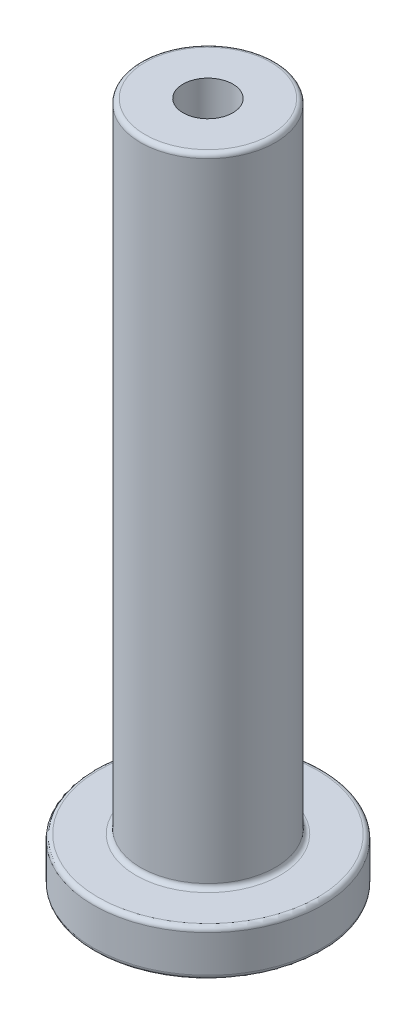
from build123d import *

# Parameters (mm, degrees)
SKETCH1_R           = 12.4
BOSS_EXTRUDE1_DEPTH = 5
SKETCH2_R           = 7.3
BOSS_EXTRUDE2_DEPTH = 69
SKETCH3_R           = 2.7
CUT_EXTRUDE1_DEPTH  = 75
CUT_EXTRUDE2_DEPTH  = 3
FILLET1_R           = 0.5


with BuildPart() as part:
    # Sketch1 → Boss-Extrude1 (new body)
    with BuildSketch(Plane(origin=(0, 0, 0), x_dir=(1, 0, 0), z_dir=(0, 1, 0))):
        Circle(SKETCH1_R)
    extrude(amount=BOSS_EXTRUDE1_DEPTH)

    # Sketch2 → Boss-Extrude2 (add)
    with BuildSketch(Plane(origin=(0, 5, 0), x_dir=(1, 0, 0), z_dir=(0, 1, 0))):
        Circle(SKETCH2_R)
    extrude(amount=BOSS_EXTRUDE2_DEPTH)

    # Sketch3 → Cut-Extrude1 (cut, through all)
    with BuildSketch(Plane(origin=(0, 74, 0), x_dir=(1, 0, 0), z_dir=(0, 1, 0))):
        Circle(SKETCH3_R)
    extrude(amount=-CUT_EXTRUDE1_DEPTH, mode=Mode.SUBTRACT)

    # Sketch4 → Cut-Extrude2 (cut)
    with BuildSketch(Plane.XZ):
        Polygon((-4.38019792, 2.081793981), (-3.992985433, -2.752465682), (0.387212487, -4.834259663), (4.38019792, -2.081793981), (3.992985433, 2.752465682), (-0.387212487, 4.834259663), align=None)
    extrude(amount=-CUT_EXTRUDE2_DEPTH, mode=Mode.SUBTRACT)

    # Fillet1
    fillet1_edges = [part.edges().sort_by_distance(p)[0] for p in [
        (-12.4, 0, 0),
        (-12.4, 5, 0),
        (-7.3, 5, 0),
        (-7.3, 74, 0),
    ]]
    fillet(fillet1_edges, radius=FILLET1_R)


solid = part.part
